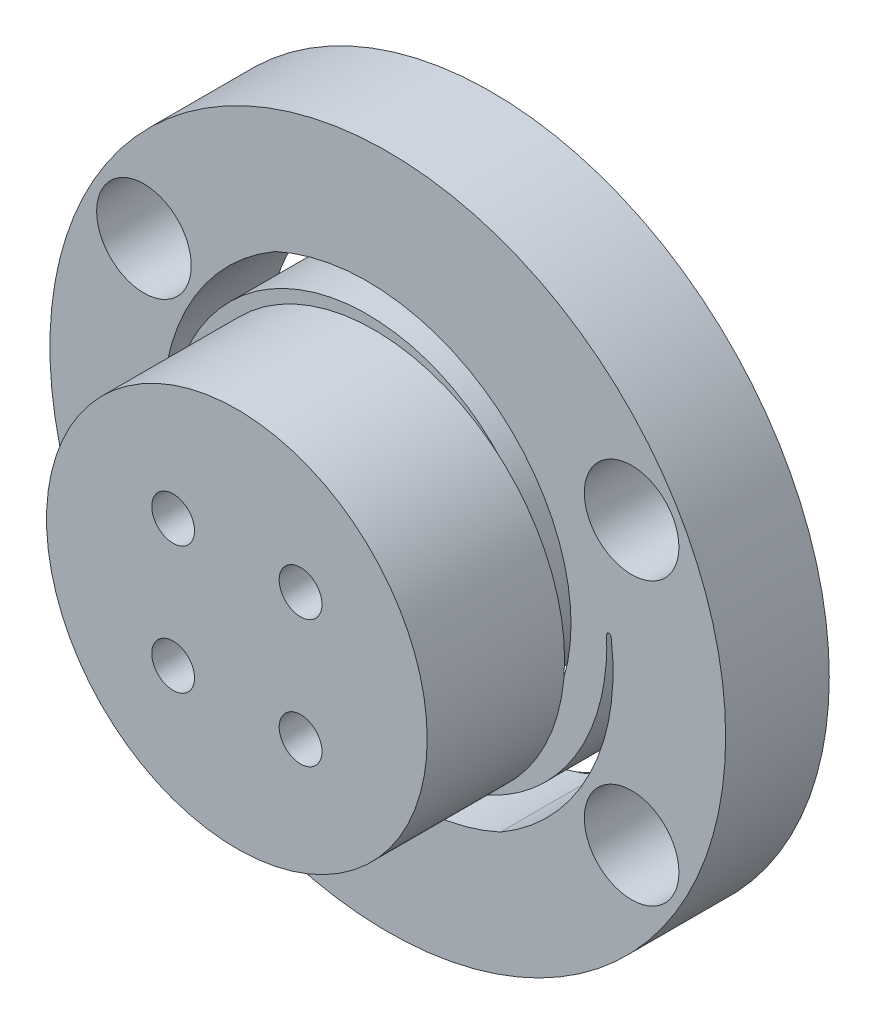
from build123d import *

# Parameters (mm, degrees)
SKETCH_2_R           = 15
SKETCH_2_R_2         = 10
EXTRUDE_2_DEPTH      = 4.6
SKETCH_23_R          = 2.1
CUT_EXTRUDE_8_DEPTH  = 3.1
SKETCH_24_R          = 1.2
CUT_EXTRUDE_9_DEPTH  = 2.5
EXTRUDE_3_DEPTH      = 4.4
SKETCH_19_R          = 4
EXTRUDE_6_DEPTH      = 3.4
SKETCH_9_R           = 3.1
CUT_EXTRUDE_1_DEPTH  = 3.1
SKETCH_10_R          = 4
EXTRUDE_4_DEPTH      = 0.6
SKETCH_11_R          = 8.45
EXTRUDE_5_DEPTH      = 2.5
FILLET_1_R           = 0.1
SKETCH_25_R          = 1
CUT_EXTRUDE_10_DEPTH = 7
CUT_EXTRUDE_11_DEPTH = 1.25
SKETCH_28_R          = 8.45
EXTRUDE_7_DEPTH      = 3.6
EXTRUDE_7_DEPTH_BACK = 2.5
SKETCH_29_R          = 0.95
CUT_EXTRUDE_12_DEPTH = 3


with BuildPart() as part:
    # Sketch 2 → Extrude 2 (new body)
    with BuildSketch(Plane.XY):
        Circle(SKETCH_2_R)
        Circle(SKETCH_2_R_2, mode=Mode.SUBTRACT)
    extrude(amount=EXTRUDE_2_DEPTH)

    # Sketch 23 → Cut-Extrude 8 (cut)
    with BuildSketch(Plane.XY.offset(4.6)):
        with Locations((10.825317547, 6.25)):
            Circle(SKETCH_23_R)
        with Locations((-10.825317547, 6.25)):
            Circle(SKETCH_23_R)
        with Locations((10.825317547, -6.25)):
            Circle(SKETCH_23_R)
        with Locations((-10.825317547, -6.25)):
            Circle(SKETCH_23_R)
    extrude(amount=-CUT_EXTRUDE_8_DEPTH, mode=Mode.SUBTRACT)

    # Sketch 24 → Cut-Extrude 9 (cut, through all)
    with BuildSketch(Plane.XY.offset(1.5)):
        with Locations((-10.825317547, 6.25)):
            Circle(SKETCH_24_R)
        with Locations((10.825317547, 6.25)):
            Circle(SKETCH_24_R)
        with Locations((10.825317547, -6.25)):
            Circle(SKETCH_24_R)
        with Locations((-10.825317547, -6.25)):
            Circle(SKETCH_24_R)
    extrude(amount=-CUT_EXTRUDE_9_DEPTH, mode=Mode.SUBTRACT)

    # Sketch 8 → Extrude 3 (add)
    with BuildSketch(Plane.XY.offset(4.6)):
        with BuildLine():
            ThreePointArc((-2.125, 3.680607966), (-3.993693638, 1.453585609), (-3.993693638, -1.453585609))
            add(Edge.make_bspline(
                [(-9.396926208, -3.420201433), (-9.732062183, -2.149175506), (-9.806172611, -0.835010365), (-9.456725912, 1.676046677), (-9.033681598, 2.871966971), (-7.789656699, 4.972884513), (-6.969506065, 5.877213907), (-5.085556702, 7.278578571), (-4.022753032, 7.775339442), (-1.834341922, 8.316896689), (-0.709724019, 8.361833006), (1.425354593, 8.02880188), (2.434991624, 7.65134079), (4.194832357, 6.566362619), (4.944502403, 5.859612911), (6.091617732, 4.253128009), (6.488888652, 3.354278704), (6.901731194, 1.519508339), (6.917493401, 0.584437672), (6.600877847, -1.174662508), (6.268999982, -1.998016278), (5.34306854, -3.416780201), (4.749719757, -4.011790899), (3.420699316, -4.904656893), (2.685804375, -5.202437862), (1.204674755, -5.486565699), (0.459151326, -5.473153796), (-0.923970423, -5.172953815), (-1.561040931, -4.886659174), (-2.638728045, -4.11977446), (-3.079079395, -3.639826603), (-3.717696054, -2.588270623), (-3.915987072, -2.017330047), (-3.993693638, -1.453585609)],
                knots=[0, 0, 0, 0, 0.0625, 0.0625, 0.125, 0.125, 0.1875, 0.1875, 0.25, 0.25, 0.3125, 0.3125, 0.375, 0.375, 0.4375, 0.4375, 0.5, 0.5, 0.5625, 0.5625, 0.625, 0.625, 0.6875, 0.6875, 0.75, 0.75, 0.8125, 0.8125, 0.875, 0.875, 0.9375, 0.9375, 1, 1, 1, 1], degree=3))
            ThreePointArc((-9.396926208, -3.420201433), (-3.420201433, -9.396926208), (5, -8.660254038))
            add(Edge.make_bspline(
                [(5, -8.660254038), (3.806479564, -9.211009881), (2.525148685, -9.512196786), (-0.008440541, -9.604099447), (-1.259652992, -9.395151506), (-3.544675532, -8.534846644), (-4.577683795, -7.884191092), (-6.284902954, -6.272207574), (-6.958670832, -5.311811899), (-7.872014208, -3.250688101), (-8.111555691, -2.150958779), (-8.154336566, 0.009513438), (-7.957931589, 1.069357245), (-7.195029811, 2.990866525), (-6.629196056, 3.851873198), (-5.246311756, 5.260524443), (-4.430103363, 5.807843469), (-2.694896637, 6.533018535), (-1.776768874, 6.710914596), (0.010586336, 6.704573685), (0.879061498, 6.520711671), (2.437057517, 5.855212978), (3.126062601, 5.37420102), (4.236145931, 4.220415939), (4.657016106, 3.548394826), (5.194022862, 2.139105174), (5.310273501, 1.402578969), (5.254810803, -0.011659233), (5.083491754, -0.688765751), (4.515396145, -1.883248509), (4.119205984, -2.400252004), (3.194520122, -3.21176742), (2.666686289, -3.506188743), (2.125, -3.680607966)],
                knots=[0, 0, 0, 0, 0.0625, 0.0625, 0.125, 0.125, 0.1875, 0.1875, 0.25, 0.25, 0.3125, 0.3125, 0.375, 0.375, 0.4375, 0.4375, 0.5, 0.5, 0.5625, 0.5625, 0.625, 0.625, 0.6875, 0.6875, 0.75, 0.75, 0.8125, 0.8125, 0.875, 0.875, 0.9375, 0.9375, 1, 1, 1, 1], degree=3))
            ThreePointArc((2.125, -3.680607966), (3.993693638, -1.453585609), (3.993693638, 1.453585609))
            add(Edge.make_bspline(
                [(9.396926208, 3.420201433), (9.732062183, 2.149175506), (9.806172611, 0.835010365), (9.456725912, -1.676046677), (9.033681598, -2.871966971), (7.789656699, -4.972884513), (6.969506065, -5.877213907), (5.085556702, -7.278578571), (4.022753032, -7.775339442), (1.834341922, -8.316896689), (0.709724019, -8.361833006), (-1.425354593, -8.02880188), (-2.434991624, -7.65134079), (-4.194832357, -6.566362619), (-4.944502403, -5.859612911), (-6.091617732, -4.253128009), (-6.488888652, -3.354278704), (-6.901731194, -1.519508339), (-6.917493401, -0.584437672), (-6.600877847, 1.174662508), (-6.268999982, 1.998016278), (-5.34306854, 3.416780201), (-4.749719757, 4.011790899), (-3.420699316, 4.904656893), (-2.685804375, 5.202437862), (-1.204674755, 5.486565699), (-0.459151326, 5.473153796), (0.923970423, 5.172953815), (1.561040931, 4.886659174), (2.638728045, 4.11977446), (3.079079395, 3.639826603), (3.717696054, 2.588270623), (3.915987072, 2.017330047), (3.993693638, 1.453585609)],
                knots=[0, 0, 0, 0, 0.0625, 0.0625, 0.125, 0.125, 0.1875, 0.1875, 0.25, 0.25, 0.3125, 0.3125, 0.375, 0.375, 0.4375, 0.4375, 0.5, 0.5, 0.5625, 0.5625, 0.625, 0.625, 0.6875, 0.6875, 0.75, 0.75, 0.8125, 0.8125, 0.875, 0.875, 0.9375, 0.9375, 1, 1, 1, 1], degree=3))
            ThreePointArc((9.396926208, 3.420201433), (3.420201433, 9.396926208), (-5, 8.660254038))
            add(Edge.make_bspline(
                [(-5, 8.660254038), (-3.806479564, 9.211009881), (-2.525148685, 9.512196786), (0.008440541, 9.604099447), (1.259652992, 9.395151506), (3.544675532, 8.534846644), (4.577683795, 7.884191092), (6.284902954, 6.272207574), (6.958670832, 5.311811899), (7.872014208, 3.250688101), (8.111555691, 2.150958779), (8.154336566, -0.009513438), (7.957931589, -1.069357245), (7.195029811, -2.990866525), (6.629196056, -3.851873198), (5.246311756, -5.260524443), (4.430103363, -5.807843469), (2.694896637, -6.533018535), (1.776768874, -6.710914596), (-0.010586336, -6.704573685), (-0.879061498, -6.520711671), (-2.437057517, -5.855212978), (-3.126062601, -5.37420102), (-4.236145931, -4.220415939), (-4.657016106, -3.548394826), (-5.194022862, -2.139105174), (-5.310273501, -1.402578969), (-5.254810803, 0.011659233), (-5.083491754, 0.688765751), (-4.515396145, 1.883248509), (-4.119205984, 2.400252004), (-3.194520122, 3.21176742), (-2.666686289, 3.506188743), (-2.125, 3.680607966)],
                knots=[0, 0, 0, 0, 0.0625, 0.0625, 0.125, 0.125, 0.1875, 0.1875, 0.25, 0.25, 0.3125, 0.3125, 0.375, 0.375, 0.4375, 0.4375, 0.5, 0.5, 0.5625, 0.5625, 0.625, 0.625, 0.6875, 0.6875, 0.75, 0.75, 0.8125, 0.8125, 0.875, 0.875, 0.9375, 0.9375, 1, 1, 1, 1], degree=3))
        make_face()
    extrude(amount=-EXTRUDE_3_DEPTH)

    # Sketch 19 → Extrude 6 (add)
    with BuildSketch(Plane(origin=(0, 0, 0.2), x_dir=(-1, 0, 0), z_dir=(0, 0, -1))):
        Circle(SKETCH_19_R)
    extrude(amount=EXTRUDE_6_DEPTH)

    # Sketch 9 → Cut-Extrude 1 (cut)
    with BuildSketch(Plane(origin=(0, 0, -3.2), x_dir=(-1, 0, 0), z_dir=(0, 0, -1))):
        Circle(SKETCH_9_R)
    extrude(amount=-CUT_EXTRUDE_1_DEPTH, mode=Mode.SUBTRACT)

    # Sketch 10 → Extrude 4 (add)
    with BuildSketch(Plane.XY.offset(4.6)):
        Circle(SKETCH_10_R)
    extrude(amount=EXTRUDE_4_DEPTH)

    # Sketch 11 → Extrude 5 (add)
    with BuildSketch(Plane.XY.offset(5.2)):
        Circle(SKETCH_11_R)
    extrude(amount=EXTRUDE_5_DEPTH)

    # Sketch 12 → Cut-Revolve 1 (revolve, cut)
    with BuildSketch(Plane(origin=(0, 0, 0), x_dir=(0, 0, -1), z_dir=(1, 0, 0))):
        Polygon((-7.7, 8.45), (-5.2, 8.45), (-6.45, 7.15), align=None)
    revolve(axis=Axis((0, 0, 0), (0, 0, 1)), mode=Mode.SUBTRACT)

    # Fillet 1
    fillet_1_edges = [part.edges().sort_by_distance(p)[0] for p in [
        (2.125, -3.680607966, 2.4),
        (-9.396926208, -3.420201433, 2.4),
        (-2.125, 3.680607966, 2.4),
        (9.396926208, 3.420201433, 2.4),
    ]]
    fillet(fillet_1_edges, radius=FILLET_1_R)

    # Sketch 25 → Cut-Extrude 10 (cut)
    with BuildSketch(Plane.XY.offset(7.7)):
        Circle(SKETCH_25_R)
    extrude(amount=-CUT_EXTRUDE_10_DEPTH, mode=Mode.SUBTRACT)

    # Sketch 26 → Cut-Extrude 11 (cut)
    with BuildSketch(Plane.XY.offset(7.7)):
        with BuildLine():
            Line((-0.2, 4.095119046), (-0.2, 9))
            Line((-0.2, 9), (0.2, 9))
            Line((0.2, 9), (0.2, 4.095119046))
            ThreePointArc((0.2, 4.095119046), (4.1, 0), (0.2, -4.095119046))
            Line((0.2, -4.095119046), (0.2, -9))
            Line((0.2, -9), (-0.2, -9))
            Line((-0.2, -9), (-0.2, -4.095119046))
            ThreePointArc((-0.2, -4.095119046), (-4.1, 0), (-0.2, 4.095119046))
        make_face()
    extrude(amount=-CUT_EXTRUDE_11_DEPTH, mode=Mode.SUBTRACT)

    # Sketch 28 → Extrude 7 (add, two sides)
    with BuildSketch(Plane.XY.offset(7.7)) as extrude_7_sk:
        Circle(SKETCH_28_R)
    extrude(amount=EXTRUDE_7_DEPTH)
    extrude(extrude_7_sk.sketch, amount=-EXTRUDE_7_DEPTH_BACK)

    # Sketch 29 → Cut-Extrude 12 (cut)
    with BuildSketch(Plane.XY.offset(11.3)):
        with Locations((-2.828427125, 2.828427125)):
            Circle(SKETCH_29_R)
        with Locations((2.828427125, 2.828427125)):
            Circle(SKETCH_29_R)
        with Locations((2.828427125, -2.828427125)):
            Circle(SKETCH_29_R)
        with Locations((-2.828427125, -2.828427125)):
            Circle(SKETCH_29_R)
    extrude(amount=-CUT_EXTRUDE_12_DEPTH, mode=Mode.SUBTRACT)


solid = part.part
